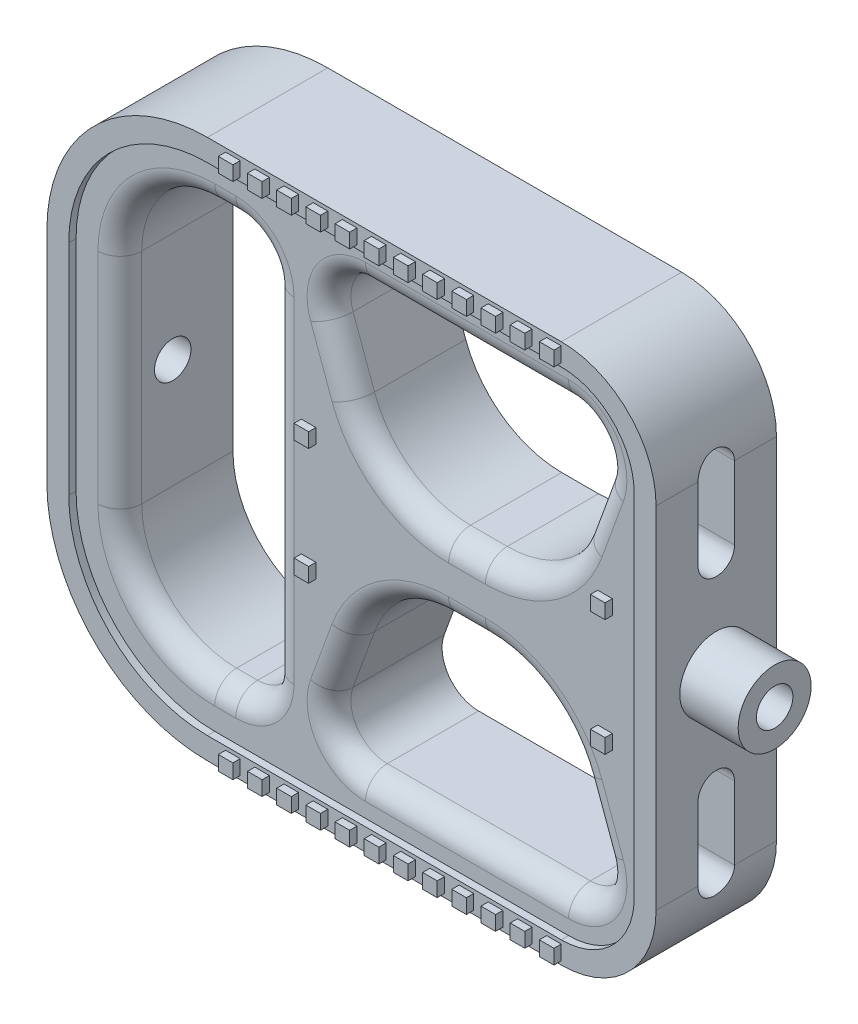
from build123d import *

# Parameters (mm, degrees)
SKETCH1_W           = 83.5
SKETCH1_H           = 74
BOSS_EXTRUDE1_DEPTH = 16.5
FILLET1_R           = 13
FILLET2_R           = 22
CUT_EXTRUDE1_DEPTH  = 1
SKETCH4_R           = 5
BOSS_EXTRUDE2_DEPTH = 8
CUT_EXTRUDE2_DEPTH  = 16.5
CUT_EXTRUDE7_REACH  = 85.5
SKETCH7_R           = 2.5
CUT_EXTRUDE9_DEPTH  = 92.5
FILLET3_R           = 3
SKETCH8_W           = 2
SKETCH8_H           = 2
BOSS_EXTRUDE4_DEPTH = 1
SKETCH9_W           = 2
SKETCH9_H           = 2
BOSS_EXTRUDE5_DEPTH = 1


with BuildPart() as part:
    # Sketch1 → Boss-Extrude1 (new body)
    with BuildSketch(Plane.XY):
        Rectangle(SKETCH1_W, SKETCH1_H)
    extrude(amount=BOSS_EXTRUDE1_DEPTH)

    # Fillet1
    fillet1_edges = [part.edges().sort_by_distance(p)[0] for p in [
        (41.75, -37, 8.25),
        (41.75, 37, 8.25),
    ]]
    fillet(fillet1_edges, radius=FILLET1_R)

    # Fillet2
    fillet2_edges = [part.edges().sort_by_distance(p)[0] for p in [
        (-41.75, -37, 8.25),
        (-41.75, 37, 8.25),
    ]]
    fillet(fillet2_edges, radius=FILLET2_R)

    # Sketch2 → Cut-Extrude1 (cut)
    with BuildSketch(Plane.XY.offset(16.5)):
        with BuildLine():
            Line((-38.75, 15), (-38.75, -15))
            ThreePointArc((-38.75, -15), (-33.185028843, -28.435028843), (-19.75, -34))
            Line((-19.75, -34), (28.75, -34))
            ThreePointArc((28.75, -34), (35.821067812, -31.071067812), (38.75, -24))
            Line((38.75, -24), (38.75, 24))
            ThreePointArc((38.75, 24), (35.821067812, 31.071067812), (28.75, 34))
            Line((28.75, 34), (-19.75, 34))
            ThreePointArc((-19.75, 34), (-33.185028843, 28.435028843), (-38.75, 15))
        make_face()
    extrude(amount=-CUT_EXTRUDE1_DEPTH, mode=Mode.SUBTRACT)

    # Sketch4 → Boss-Extrude2 (add)
    with BuildSketch(Plane(origin=(41.75, 0, 0), x_dir=(0, 0, -1), z_dir=(1, 0, 0))):
        with Locations((-8.25, 0)):
            Circle(SKETCH4_R)
    extrude(amount=BOSS_EXTRUDE2_DEPTH)

    # Sketch6 → Cut-Extrude2 (cut, through all)
    with BuildSketch(Plane.XY.offset(15.5)):
        with BuildLine():
            Line((-19.75, 28), (-16.875, 28))
            ThreePointArc((-16.875, 28), (-13.339466094, 26.535533906), (-11.875, 23))
            Line((-11.875, 23), (-11.875, -23))
            ThreePointArc((-11.875, -23), (-13.339466094, -26.535533906), (-16.875, -28))
            Line((-16.875, -28), (-19.75, -28))
            ThreePointArc((-19.75, -28), (-28.942388155, -24.192388155), (-32.75, -15))
            Line((-32.75, -15), (-32.75, 15))
            ThreePointArc((-32.75, 15), (-28.942388155, 24.192388155), (-19.75, 28))
        make_face()
        with BuildLine():
            Line((0.916666667, 29), (28.75, 29))
            ThreePointArc((28.75, 29), (32.845760221, 26.867882182), (33.448463104, 22.289899283))
            Line((33.448463104, 22.289899283), (30.508245567, 14.211717993))
            ThreePointArc((30.508245567, 14.211717993), (25.382618985, 7.53187138), (17.352548876, 5))
            Line((17.352548876, 5), (12.31411779, 5))
            ThreePointArc((12.31411779, 5), (4.284047681, 7.53187138), (-0.841578901, 14.211717993))
            Line((-0.841578901, 14.211717993), (-3.781796437, 22.289899283))
            ThreePointArc((-3.781796437, 22.289899283), (-3.179093555, 26.867882182), (0.916666667, 29))
        make_face()
        with BuildLine():
            Line((17.352548876, -5), (12.31411779, -5))
            ThreePointArc((12.31411779, -5), (4.284047681, -7.53187138), (-0.841578901, -14.211717993))
            Line((-0.841578901, -14.211717993), (-3.781796437, -22.289899283))
            ThreePointArc((-3.781796437, -22.289899283), (-3.179093555, -26.867882182), (0.916666667, -29))
            Line((0.916666667, -29), (28.75, -29))
            ThreePointArc((28.75, -29), (32.845760221, -26.867882182), (33.448463104, -22.289899283))
            Line((33.448463104, -22.289899283), (30.508245567, -14.211717993))
            ThreePointArc((30.508245567, -14.211717993), (25.382618985, -7.53187138), (17.352548876, -5))
        make_face()
    extrude(amount=-CUT_EXTRUDE2_DEPTH, mode=Mode.SUBTRACT)

    # Sketch5 → Cut-Extrude7 (cut, up to next)
    with BuildSketch(Plane(origin=(41.75, 0, 0), x_dir=(0, 0, -1), z_dir=(1, 0, 0)), mode=Mode.PRIVATE) as cut_extrude7_sk1:
        with BuildLine():
            Line((-5.75, 24), (-5.75, 14))
            ThreePointArc((-5.75, 14), (-8.25, 11.5), (-10.75, 14))
            Line((-10.75, 14), (-10.75, 24))
            ThreePointArc((-10.75, 24), (-8.25, 26.5), (-5.75, 24))
        make_face()
    cut_extrude7_tool1 = extrude(cut_extrude7_sk1.sketch, amount=-CUT_EXTRUDE7_REACH, mode=Mode.PRIVATE) & part.part
    add(cut_extrude7_tool1.solids().sort_by_distance((41.75, 19, 8.25))[0], mode=Mode.SUBTRACT)
    # Sketch5 → Cut-Extrude7 (cut, up to next)
    with BuildSketch(Plane(origin=(41.75, 0, 0), x_dir=(0, 0, -1), z_dir=(1, 0, 0)), mode=Mode.PRIVATE) as cut_extrude7_sk2:
        with BuildLine():
            Line((-5.75, -24), (-5.75, -14))
            ThreePointArc((-5.75, -14), (-8.25, -11.5), (-10.75, -14))
            Line((-10.75, -14), (-10.75, -24))
            ThreePointArc((-10.75, -24), (-8.25, -26.5), (-5.75, -24))
        make_face()
    cut_extrude7_tool2 = extrude(cut_extrude7_sk2.sketch, amount=-CUT_EXTRUDE7_REACH, mode=Mode.PRIVATE) & part.part
    add(cut_extrude7_tool2.solids().sort_by_distance((41.75, -19, 8.25))[0], mode=Mode.SUBTRACT)

    # Sketch7 → Cut-Extrude9 (cut, through all)
    with BuildSketch(Plane(origin=(49.75, 0, 0), x_dir=(0, 0, -1), z_dir=(1, 0, 0))):
        with Locations((-8.25, 0)):
            Circle(SKETCH7_R)
    extrude(amount=-CUT_EXTRUDE9_DEPTH, mode=Mode.SUBTRACT)

    # Fillet3
    fillet3_edges = [part.edges().sort_by_distance(p)[0] for p in [
        (-13.339466094, -26.535533906, 15.5),
        (-28.942388155, 24.192388155, 15.5),
        (4.284047681, 7.53187138, 15.5),
        (-2.311687669, 18.250808638, 15.5),
        (14.833333333, 29, 15.5),
        (32.845760221, 26.867882182, 15.5),
        (31.978354336, 18.250808638, 15.5),
        (25.382618985, 7.53187138, 15.5),
        (14.833333333, 5, 15.5),
        (-3.179093555, 26.867882182, 15.5),
        (25.382618985, -7.53187138, 15.5),
        (-3.179093555, -26.867882182, 15.5),
        (14.833333333, -5, 15.5),
        (4.284047681, -7.53187138, 15.5),
        (-2.311687669, -18.250808638, 15.5),
        (14.833333333, -29, 15.5),
        (32.845760221, -26.867882182, 15.5),
        (31.978354336, -18.250808638, 15.5),
        (-18.3125, 28, 15.5),
        (-13.339466094, 26.535533906, 15.5),
        (-11.875, 0, 15.5),
        (-32.75, 0, 15.5),
        (-28.942388155, -24.192388155, 15.5),
        (-18.3125, -28, 15.5),
    ]]
    fillet(fillet3_edges, radius=FILLET3_R)

    # Sketch8 → Boss-Extrude4 (add)
    with BuildSketch(Plane.XY.offset(15.5)):
        with Locations((-6.875, -8)):
            Rectangle(SKETCH8_W, SKETCH8_H)
        with Locations((33.75, -8)):
            Rectangle(SKETCH8_W, SKETCH8_H)
        with Locations((33.75, 8)):
            Rectangle(SKETCH8_W, SKETCH8_H)
        with Locations((-6.875, 8)):
            Rectangle(SKETCH8_W, SKETCH8_H)
        with Locations((27.75, 35.5)):
            Rectangle(SKETCH8_W, SKETCH8_H)
        with Locations((23.75, 35.5)):
            Rectangle(SKETCH8_W, SKETCH8_H)
        with Locations((19.75, 35.5)):
            Rectangle(SKETCH8_W, SKETCH8_H)
        with Locations((15.75, 35.5)):
            Rectangle(SKETCH8_W, SKETCH8_H)
        with Locations((11.75, 35.5)):
            Rectangle(SKETCH8_W, SKETCH8_H)
        with Locations((7.75, 35.5)):
            Rectangle(SKETCH8_W, SKETCH8_H)
        with Locations((3.75, 35.5)):
            Rectangle(SKETCH8_W, SKETCH8_H)
        with Locations((-0.25, 35.5)):
            Rectangle(SKETCH8_W, SKETCH8_H)
        with Locations((-4.25, 35.5)):
            Rectangle(SKETCH8_W, SKETCH8_H)
        with Locations((-8.25, 35.5)):
            Rectangle(SKETCH8_W, SKETCH8_H)
        with Locations((-12.25, 35.5)):
            Rectangle(SKETCH8_W, SKETCH8_H)
        with Locations((-16.25, 35.5)):
            Rectangle(SKETCH8_W, SKETCH8_H)
        with Locations((27.75, -35.5)):
            Rectangle(SKETCH8_W, SKETCH8_H)
        with Locations((23.75, -35.5)):
            Rectangle(SKETCH8_W, SKETCH8_H)
        with Locations((19.75, -35.5)):
            Rectangle(SKETCH8_W, SKETCH8_H)
        with Locations((15.75, -35.5)):
            Rectangle(SKETCH8_W, SKETCH8_H)
        with Locations((11.75, -35.5)):
            Rectangle(SKETCH8_W, SKETCH8_H)
        with Locations((7.75, -35.5)):
            Rectangle(SKETCH8_W, SKETCH8_H)
        with Locations((3.75, -35.5)):
            Rectangle(SKETCH8_W, SKETCH8_H)
        with Locations((-0.25, -35.5)):
            Rectangle(SKETCH8_W, SKETCH8_H)
        with Locations((-4.25, -35.5)):
            Rectangle(SKETCH8_W, SKETCH8_H)
        with Locations((-8.25, -35.5)):
            Rectangle(SKETCH8_W, SKETCH8_H)
        with Locations((-12.25, -35.5)):
            Rectangle(SKETCH8_W, SKETCH8_H)
        with Locations((-16.25, -35.5)):
            Rectangle(SKETCH8_W, SKETCH8_H)
    extrude(amount=BOSS_EXTRUDE4_DEPTH)

    # Sketch9 → Boss-Extrude5 (add)
    with BuildSketch(Plane.XY.offset(16.5)):
        with Locations((27.75, 35.5)):
            Rectangle(SKETCH9_W, SKETCH9_H)
        with Locations((27.75, -35.5)):
            Rectangle(SKETCH9_W, SKETCH9_H)
        with Locations((23.75, 35.5)):
            Rectangle(SKETCH9_W, SKETCH9_H)
        with Locations((23.75, -35.5)):
            Rectangle(SKETCH9_W, SKETCH9_H)
        with Locations((19.75, 35.5)):
            Rectangle(SKETCH9_W, SKETCH9_H)
        with Locations((19.75, -35.5)):
            Rectangle(SKETCH9_W, SKETCH9_H)
        with Locations((15.75, 35.5)):
            Rectangle(SKETCH9_W, SKETCH9_H)
        with Locations((15.75, -35.5)):
            Rectangle(SKETCH9_W, SKETCH9_H)
        with Locations((11.75, 35.5)):
            Rectangle(SKETCH9_W, SKETCH9_H)
        with Locations((11.75, -35.5)):
            Rectangle(SKETCH9_W, SKETCH9_H)
        with Locations((7.75, 35.5)):
            Rectangle(SKETCH9_W, SKETCH9_H)
        with Locations((7.75, -35.5)):
            Rectangle(SKETCH9_W, SKETCH9_H)
        with Locations((3.75, 35.5)):
            Rectangle(SKETCH9_W, SKETCH9_H)
        with Locations((3.75, -35.5)):
            Rectangle(SKETCH9_W, SKETCH9_H)
        with Locations((-0.25, 35.5)):
            Rectangle(SKETCH9_W, SKETCH9_H)
        with Locations((-0.25, -35.5)):
            Rectangle(SKETCH9_W, SKETCH9_H)
        with Locations((-4.25, 35.5)):
            Rectangle(SKETCH9_W, SKETCH9_H)
        with Locations((-4.25, -35.5)):
            Rectangle(SKETCH9_W, SKETCH9_H)
        with Locations((-8.25, 35.5)):
            Rectangle(SKETCH9_W, SKETCH9_H)
        with Locations((-8.25, -35.5)):
            Rectangle(SKETCH9_W, SKETCH9_H)
        with Locations((-12.25, 35.5)):
            Rectangle(SKETCH9_W, SKETCH9_H)
        with Locations((-12.25, -35.5)):
            Rectangle(SKETCH9_W, SKETCH9_H)
        with Locations((-16.25, 35.5)):
            Rectangle(SKETCH9_W, SKETCH9_H)
        with Locations((-16.25, -35.5)):
            Rectangle(SKETCH9_W, SKETCH9_H)
    extrude(amount=BOSS_EXTRUDE5_DEPTH)


solid = part.part
